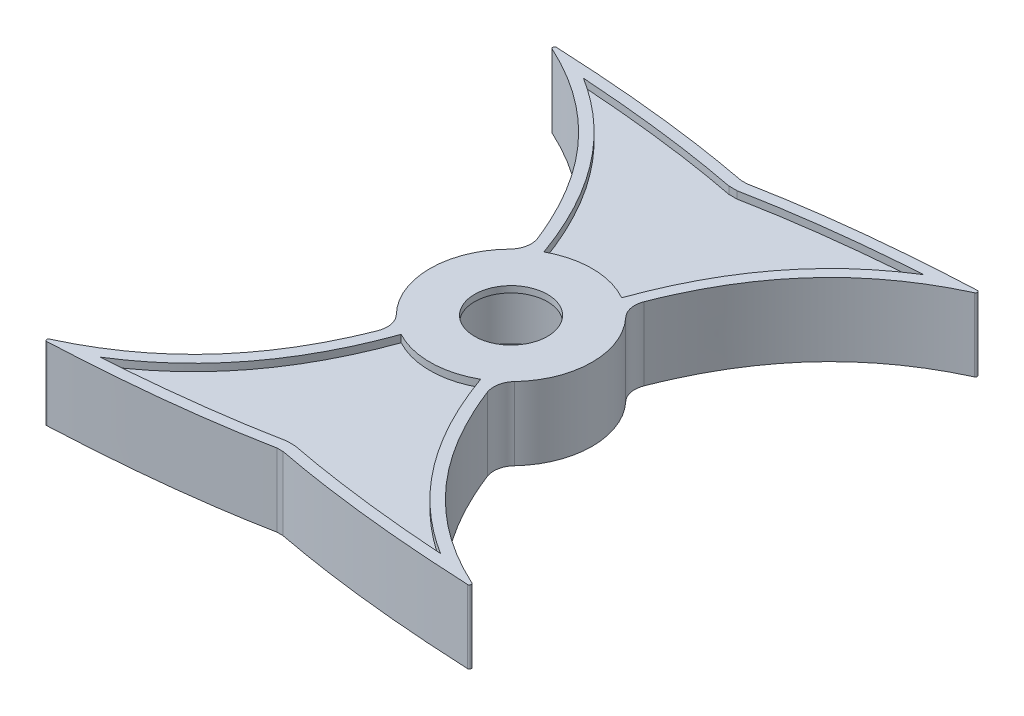
from build123d import *

# Parameters (mm, degrees)
BOSS_EXTRUDE1_DEPTH     = 5
BOSS_EXTRUDE2_DEPTH     = 5
CUT_EXTRUDE2_DEPTH      = 1
CUT_EXTRUDE3_DEPTH      = 77.926135777
CUT_EXTRUDE3_DEPTH_BACK = 77.926135777
FILLET1_R               = 0.25
CUT_EXTRUDE4_START      = -10
CUT_EXTRUDE4_DEPTH      = 1
SKETCH16_R              = 11.125
BOSS_EXTRUDE3_DEPTH     = 5
FILLET2_R               = 3
SKETCH16_3_R            = 8.125
SKETCH16_3_R_2          = 5
CUT_EXTRUDE5_DEPTH      = 4.125
SKETCH16_4_R            = 5
CUT_EXTRUDE6_DEPTH      = 76.97165183
CUT_EXTRUDE6_DEPTH_BACK = 76.97165183


with BuildPart() as part:
    # Sketch2 → Boss-Extrude1 (new, symmetric)
    with BuildSketch(Plane(origin=(0, 0, 0), x_dir=(1, 0, 0), z_dir=(0, 1, 0))):
        with BuildLine():
            add(Edge.make_bspline(
                [(5.058042735, 38.105157157), (3.146372832, 43.741321053), (0.130284217, 48.940308155)],
                knots=[0, 0, 0, 1, 1, 1], degree=2))
            Line((0.130284217, 48.940308155), (0.130284217, 0))
            Line((0.130284217, 0), (0.260568434, 0))
            add(Edge.make_bspline(
                [(5.058042735, 38.105157157), (1.841597364, 25.695767452), (1.424721162, 11.959182325), (0.260568434, 0)],
                knots=[0.522378338, 0.522378338, 0.522378338, 0.522378338, 1, 1, 1, 1], degree=3))
        make_face()
        with BuildLine():
            Line((0.130284217, 0), (0.130284217, 48.940308155))
            add(Edge.make_bspline(
                [(-4.797474301, 38.105157157), (-2.885804398, 43.741321053), (0.130284217, 48.940308155)],
                knots=[0, 0, 0, 1, 1, 1], degree=2))
            add(Edge.make_bspline(
                [(-4.797474301, 38.105157157), (-1.58102893, 25.695767452), (-1.164152728, 11.959182325), (0, 0)],
                knots=[0.522378338, 0.522378338, 0.522378338, 0.522378338, 1, 1, 1, 1], degree=3))
            Line((0, 0), (0.130284217, 0))
        make_face()
        with BuildLine():
            add(Edge.make_bspline(
                [(-4.797474301, 38.105157157), (-2.885804398, 43.741321053), (0.130284217, 48.940308155)],
                knots=[0, 0, 0, 1, 1, 1], degree=2))
            add(Edge.make_bspline(
                [(-5.284185414, 56.665905019), (-2.134774898, 53.195096173), (0.130284217, 48.940308155)],
                knots=[0.737966039, 0.737966039, 0.737966039, 1, 1, 1], degree=2))
            add(Edge.make_bspline(
                [(-9.954353034, 51.660616755), (-7.85501617, 54.382545798), (-5.284185414, 56.665905019)],
                knots=[0, 0, 0, 0.508320354, 0.508320354, 0.508320354], degree=2))
            add(Edge.make_bspline(
                [(-9.954353034, 51.660616755), (-7.686471873, 47.456371568), (-6.034820164, 42.878969621), (-4.797474301, 38.105157157)],
                knots=[0.338640354, 0.338640354, 0.338640354, 0.338640354, 0.522378338, 0.522378338, 0.522378338, 0.522378338], degree=3))
        make_face()
        with BuildLine():
            Line((0.130284217, 48.940308155), (0.130284217, 60.672799159))
            add(Edge.make_bspline(
                [(-5.284185414, 56.665905019), (-2.797515059, 58.874514696), (0.130284217, 60.672799159)],
                knots=[0.508320354, 0.508320354, 0.508320354, 1, 1, 1], degree=2))
            add(Edge.make_bspline(
                [(-5.284185414, 56.665905019), (-2.134774898, 53.195096173), (0.130284217, 48.940308155)],
                knots=[0.737966039, 0.737966039, 0.737966039, 1, 1, 1], degree=2))
        make_face()
        with BuildLine():
            add(Edge.make_bspline(
                [(5.544753848, 56.665905019), (3.058083493, 58.874514696), (0.130284217, 60.672799159)],
                knots=[0.508320354, 0.508320354, 0.508320354, 1, 1, 1], degree=2))
            Line((0.130284217, 60.672799159), (0.130284217, 48.940308155))
            add(Edge.make_bspline(
                [(5.544753848, 56.665905019), (2.395343332, 53.195096173), (0.130284217, 48.940308155)],
                knots=[0.737966039, 0.737966039, 0.737966039, 1, 1, 1], degree=2))
        make_face()
        with BuildLine():
            add(Edge.make_bspline(
                [(5.544753848, 56.665905019), (2.395343332, 53.195096173), (0.130284217, 48.940308155)],
                knots=[0.737966039, 0.737966039, 0.737966039, 1, 1, 1], degree=2))
            add(Edge.make_bspline(
                [(5.058042735, 38.105157157), (3.146372832, 43.741321053), (0.130284217, 48.940308155)],
                knots=[0, 0, 0, 1, 1, 1], degree=2))
            add(Edge.make_bspline(
                [(10.214921468, 51.660616755), (7.947040307, 47.456371568), (6.295388597, 42.878969621), (5.058042735, 38.105157157)],
                knots=[0.338640354, 0.338640354, 0.338640354, 0.338640354, 0.522378338, 0.522378338, 0.522378338, 0.522378338], degree=3))
            add(Edge.make_bspline(
                [(10.214921468, 51.660616755), (8.115584604, 54.382545798), (5.544753848, 56.665905019)],
                knots=[0, 0, 0, 0.508320354, 0.508320354, 0.508320354], degree=2))
        make_face()
        with BuildLine():
            add(Edge.make_bspline(
                [(12.371854568, 62.583668492), (8.55448151, 59.982776333), (5.544753848, 56.665905019)],
                knots=[0.487553825, 0.487553825, 0.487553825, 0.737966039, 0.737966039, 0.737966039], degree=2))
            add(Edge.make_bspline(
                [(10.214921468, 51.660616755), (8.115584604, 54.382545798), (5.544753848, 56.665905019)],
                knots=[0, 0, 0, 0.508320354, 0.508320354, 0.508320354], degree=2))
            add(Edge.make_bspline(
                [(16.684475146, 60.672799159), (14.096083486, 57.947112928), (11.970804186, 54.915708597), (10.214921468, 51.660616755)],
                knots=[0.196383186, 0.196383186, 0.196383186, 0.196383186, 0.338640354, 0.338640354, 0.338640354, 0.338640354], degree=3))
            add(Edge.make_bspline(
                [(12.371854568, 62.583668492), (14.552793974, 61.680828431), (16.684475146, 60.672799159)],
                knots=[0.731382858, 0.731382858, 0.731382858, 1, 1, 1], degree=2))
        make_face()
        with BuildLine():
            add(Edge.make_bspline(
                [(7.660000207, 64.391156365), (3.798429333, 62.755657085), (0.130284217, 60.672799159)],
                knots=[0.732822154, 0.732822154, 0.732822154, 1, 1, 1], degree=2))
            add(Edge.make_bspline(
                [(5.544753848, 56.665905019), (3.058083493, 58.874514696), (0.130284217, 60.672799159)],
                knots=[0.508320354, 0.508320354, 0.508320354, 1, 1, 1], degree=2))
            add(Edge.make_bspline(
                [(12.371854568, 62.583668492), (8.55448151, 59.982776333), (5.544753848, 56.665905019)],
                knots=[0.487553825, 0.487553825, 0.487553825, 0.737966039, 0.737966039, 0.737966039], degree=2))
            add(Edge.make_bspline(
                [(7.660000207, 64.391156365), (10.04398678, 63.547332265), (12.371854568, 62.583668492)],
                knots=[0.444669165, 0.444669165, 0.444669165, 0.731382858, 0.731382858, 0.731382858], degree=2))
        make_face()
        with BuildLine():
            add(Edge.make_bspline(
                [(30.29838823, 69.997414324), (24.713486318, 67.615695548), (20.257698272, 64.435554705), (16.684475146, 60.672799159)],
                knots=[0, 0, 0, 0, 0.196383186, 0.196383186, 0.196383186, 0.196383186], degree=3))
            add(Edge.make_bspline(
                [(30.29838823, 69.997414324), (19.804298872, 67.647618444), (12.371854568, 62.583668492)],
                knots=[0, 0, 0, 0.487553825, 0.487553825, 0.487553825], degree=2))
            add(Edge.make_bspline(
                [(12.371854568, 62.583668492), (14.552793974, 61.680828431), (16.684475146, 60.672799159)],
                knots=[0.731382858, 0.731382858, 0.731382858, 1, 1, 1], degree=2))
        make_face()
        with BuildLine():
            add(Edge.make_bspline(
                [(30.29838823, 69.997414324), (18.251614468, 68.877045154), (7.660000207, 64.391156365)],
                knots=[0, 0, 0, 0.732822154, 0.732822154, 0.732822154], degree=2))
            add(Edge.make_bspline(
                [(7.660000207, 64.391156365), (10.04398678, 63.547332265), (12.371854568, 62.583668492)],
                knots=[0.444669165, 0.444669165, 0.444669165, 0.731382858, 0.731382858, 0.731382858], degree=2))
            add(Edge.make_bspline(
                [(30.29838823, 69.997414324), (19.804298872, 67.647618444), (12.371854568, 62.583668492)],
                knots=[0, 0, 0, 0.487553825, 0.487553825, 0.487553825], degree=2))
        make_face()
        with BuildLine():
            add(Edge.make_bspline(
                [(30.29838823, 69.997414324), (20.531757919, 69.599100635), (10.054304676, 68.677577885), (0.130284217, 66.720303176)],
                knots=[0, 0, 0, 0, 1, 1, 1, 1], degree=3))
            add(Edge.make_bspline(
                [(0.130284217, 66.720303176), (3.962634698, 65.699857578), (7.660000207, 64.391156365)],
                knots=[0, 0, 0, 0.444669165, 0.444669165, 0.444669165], degree=2))
            add(Edge.make_bspline(
                [(30.29838823, 69.997414324), (18.251614468, 68.877045154), (7.660000207, 64.391156365)],
                knots=[0, 0, 0, 0.732822154, 0.732822154, 0.732822154], degree=2))
        make_face()
        with BuildLine():
            add(Edge.make_bspline(
                [(0.130284217, 66.720303176), (3.962634698, 65.699857578), (7.660000207, 64.391156365)],
                knots=[0, 0, 0, 0.444669165, 0.444669165, 0.444669165], degree=2))
            Line((0.130284217, 66.720303176), (0.130284217, 60.672799159))
            add(Edge.make_bspline(
                [(7.660000207, 64.391156365), (3.798429333, 62.755657085), (0.130284217, 60.672799159)],
                knots=[0.732822154, 0.732822154, 0.732822154, 1, 1, 1], degree=2))
        make_face()
        with BuildLine():
            Line((0.130284217, 60.672799159), (0.130284217, 66.720303176))
            add(Edge.make_bspline(
                [(0.130284217, 66.720303176), (-3.702066264, 65.699857578), (-7.399431773, 64.391156365)],
                knots=[0, 0, 0, 0.444669165, 0.444669165, 0.444669165], degree=2))
            add(Edge.make_bspline(
                [(-7.399431773, 64.391156365), (-3.537860899, 62.755657085), (0.130284217, 60.672799159)],
                knots=[0.732822154, 0.732822154, 0.732822154, 1, 1, 1], degree=2))
        make_face()
        with BuildLine():
            add(Edge.make_bspline(
                [(-5.284185414, 56.665905019), (-2.797515059, 58.874514696), (0.130284217, 60.672799159)],
                knots=[0.508320354, 0.508320354, 0.508320354, 1, 1, 1], degree=2))
            add(Edge.make_bspline(
                [(-7.399431773, 64.391156365), (-3.537860899, 62.755657085), (0.130284217, 60.672799159)],
                knots=[0.732822154, 0.732822154, 0.732822154, 1, 1, 1], degree=2))
            add(Edge.make_bspline(
                [(-7.399431773, 64.391156365), (-9.783418346, 63.547332265), (-12.111286134, 62.583668492)],
                knots=[0.444669165, 0.444669165, 0.444669165, 0.731382858, 0.731382858, 0.731382858], degree=2))
            add(Edge.make_bspline(
                [(-12.111286134, 62.583668492), (-8.293913076, 59.982776333), (-5.284185414, 56.665905019)],
                knots=[0.487553825, 0.487553825, 0.487553825, 0.737966039, 0.737966039, 0.737966039], degree=2))
        make_face()
        with BuildLine():
            add(Edge.make_bspline(
                [(-9.954353034, 51.660616755), (-7.85501617, 54.382545798), (-5.284185414, 56.665905019)],
                knots=[0, 0, 0, 0.508320354, 0.508320354, 0.508320354], degree=2))
            add(Edge.make_bspline(
                [(-12.111286134, 62.583668492), (-8.293913076, 59.982776333), (-5.284185414, 56.665905019)],
                knots=[0.487553825, 0.487553825, 0.487553825, 0.737966039, 0.737966039, 0.737966039], degree=2))
            add(Edge.make_bspline(
                [(-12.111286134, 62.583668492), (-14.29222554, 61.680828431), (-16.423906712, 60.672799159)],
                knots=[0.731382858, 0.731382858, 0.731382858, 1, 1, 1], degree=2))
            add(Edge.make_bspline(
                [(-16.423906712, 60.672799159), (-13.835515052, 57.947112928), (-11.710235752, 54.915708597), (-9.954353034, 51.660616755)],
                knots=[0.196383186, 0.196383186, 0.196383186, 0.196383186, 0.338640354, 0.338640354, 0.338640354, 0.338640354], degree=3))
        make_face()
        with BuildLine():
            add(Edge.make_bspline(
                [(-30.037819796, 69.997414324), (-19.543730438, 67.647618444), (-12.111286134, 62.583668492)],
                knots=[0, 0, 0, 0.487553825, 0.487553825, 0.487553825], degree=2))
            add(Edge.make_bspline(
                [(-30.037819796, 69.997414324), (-24.452917884, 67.615695548), (-19.997129838, 64.435554705), (-16.423906712, 60.672799159)],
                knots=[0, 0, 0, 0, 0.196383186, 0.196383186, 0.196383186, 0.196383186], degree=3))
            add(Edge.make_bspline(
                [(-12.111286134, 62.583668492), (-14.29222554, 61.680828431), (-16.423906712, 60.672799159)],
                knots=[0.731382858, 0.731382858, 0.731382858, 1, 1, 1], degree=2))
        make_face()
        with BuildLine():
            add(Edge.make_bspline(
                [(-7.399431773, 64.391156365), (-9.783418346, 63.547332265), (-12.111286134, 62.583668492)],
                knots=[0.444669165, 0.444669165, 0.444669165, 0.731382858, 0.731382858, 0.731382858], degree=2))
            add(Edge.make_bspline(
                [(-30.037819796, 69.997414324), (-17.991046034, 68.877045154), (-7.399431773, 64.391156365)],
                knots=[0, 0, 0, 0.732822154, 0.732822154, 0.732822154], degree=2))
            add(Edge.make_bspline(
                [(-30.037819796, 69.997414324), (-19.543730438, 67.647618444), (-12.111286134, 62.583668492)],
                knots=[0, 0, 0, 0.487553825, 0.487553825, 0.487553825], degree=2))
        make_face()
        with BuildLine():
            add(Edge.make_bspline(
                [(0.130284217, 66.720303176), (-3.702066264, 65.699857578), (-7.399431773, 64.391156365)],
                knots=[0, 0, 0, 0.444669165, 0.444669165, 0.444669165], degree=2))
            add(Edge.make_bspline(
                [(-30.037819796, 69.997414324), (-20.271189485, 69.599100635), (-9.793736242, 68.677577885), (0.130284217, 66.720303176)],
                knots=[0, 0, 0, 0, 1, 1, 1, 1], degree=3))
            add(Edge.make_bspline(
                [(-30.037819796, 69.997414324), (-17.991046034, 68.877045154), (-7.399431773, 64.391156365)],
                knots=[0, 0, 0, 0.732822154, 0.732822154, 0.732822154], degree=2))
        make_face()
    extrude(amount=BOSS_EXTRUDE1_DEPTH, both=True)

    # Sketch3 → Boss-Extrude2 (add, symmetric)
    with BuildSketch(Plane(origin=(0, 0, 0), x_dir=(1, 0, 0), z_dir=(0, 1, 0))):
        with BuildLine():
            Line((0.260568365, 69.997414339), (7e-08, 69.99741433))
            add(Edge.make_bspline(
                [(-4.797474263, 31.892257053), (-1.581028863, 44.301646789), (-1.164152663, 58.038231966), (7e-08, 69.99741433)],
                knots=[0.522378336, 0.522378336, 0.522378336, 0.522378336, 1, 1, 1, 1], degree=3))
            add(Edge.make_bspline(
                [(-4.797474263, 31.892257053), (-2.885804367, 26.256093217), (0.130284218, 21.057106167)],
                knots=[0, 0, 0, 1, 1, 1], degree=2))
            add(Edge.make_bspline(
                [(5.058042699, 31.892257059), (3.146372802, 26.25609322), (0.130284218, 21.057106167)],
                knots=[0, 0, 0, 1, 1, 1], degree=2))
            add(Edge.make_bspline(
                [(5.058042699, 31.892257059), (1.841597298, 44.301646796), (1.424721098, 58.038231974), (0.260568365, 69.997414339)],
                knots=[0.522378336, 0.522378336, 0.522378336, 0.522378336, 1, 1, 1, 1], degree=3))
        make_face()
        with BuildLine():
            add(Edge.make_bspline(
                [(-4.797474263, 31.892257053), (-2.885804367, 26.256093217), (0.130284218, 21.057106167)],
                knots=[0, 0, 0, 1, 1, 1], degree=2))
            add(Edge.make_bspline(
                [(-9.954352995, 18.336797518), (-7.686471838, 22.541042685), (-6.034820127, 27.118444611), (-4.797474263, 31.892257053)],
                knots=[0.338640353, 0.338640353, 0.338640353, 0.338640353, 0.522378336, 0.522378336, 0.522378336, 0.522378336], degree=3))
            add(Edge.make_bspline(
                [(-9.954352995, 18.336797518), (-7.855016146, 15.614868504), (-5.284185413, 13.331509304)],
                knots=[0, 0, 0, 0.508320352, 0.508320352, 0.508320352], degree=2))
            add(Edge.make_bspline(
                [(-5.284185413, 13.331509304), (-2.134774897, 16.802318149), (0.130284218, 21.057106167)],
                knots=[0.737966039, 0.737966039, 0.737966039, 1, 1, 1], degree=2))
        make_face()
        with BuildLine():
            add(Edge.make_bspline(
                [(10.214921433, 18.336797522), (7.947040274, 22.54104269), (6.295388563, 27.118444616), (5.058042699, 31.892257059)],
                knots=[0.338640353, 0.338640353, 0.338640353, 0.338640353, 0.522378336, 0.522378336, 0.522378336, 0.522378336], degree=3))
            add(Edge.make_bspline(
                [(5.058042699, 31.892257059), (3.146372802, 26.25609322), (0.130284218, 21.057106167)],
                knots=[0, 0, 0, 1, 1, 1], degree=2))
            add(Edge.make_bspline(
                [(5.544753848, 13.331509305), (2.395343333, 16.80231815), (0.130284218, 21.057106167)],
                knots=[0.737966039, 0.737966039, 0.737966039, 1, 1, 1], degree=2))
            add(Edge.make_bspline(
                [(10.214921433, 18.336797522), (8.115584582, 15.614868506), (5.544753848, 13.331509305)],
                knots=[0, 0, 0, 0.508320352, 0.508320352, 0.508320352], degree=2))
        make_face()
        with BuildLine():
            add(Edge.make_bspline(
                [(5.544753848, 13.331509305), (2.395343333, 16.80231815), (0.130284218, 21.057106167)],
                knots=[0.737966039, 0.737966039, 0.737966039, 1, 1, 1], degree=2))
            add(Edge.make_bspline(
                [(-5.284185413, 13.331509304), (-2.134774897, 16.802318149), (0.130284218, 21.057106167)],
                knots=[0.737966039, 0.737966039, 0.737966039, 1, 1, 1], degree=2))
            add(Edge.make_bspline(
                [(-5.284185413, 13.331509304), (-2.797515058, 11.122899628), (0.130284217, 9.324615165)],
                knots=[0.508320352, 0.508320352, 0.508320352, 1, 1, 1], degree=2))
            add(Edge.make_bspline(
                [(5.544753848, 13.331509305), (3.058083493, 11.122899628), (0.130284217, 9.324615165)],
                knots=[0.508320352, 0.508320352, 0.508320352, 1, 1, 1], degree=2))
        make_face()
        with BuildLine():
            add(Edge.make_bspline(
                [(16.684475107, 9.324615149), (14.09608345, 12.050301371), (11.970804151, 15.081705692), (10.214921433, 18.336797522)],
                knots=[0.196383186, 0.196383186, 0.196383186, 0.196383186, 0.338640353, 0.338640353, 0.338640353, 0.338640353], degree=3))
            add(Edge.make_bspline(
                [(10.214921433, 18.336797522), (8.115584582, 15.614868506), (5.544753848, 13.331509305)],
                knots=[0, 0, 0, 0.508320352, 0.508320352, 0.508320352], degree=2))
            add(Edge.make_bspline(
                [(12.371854568, 7.413745832), (8.55448151, 10.014637991), (5.544753848, 13.331509305)],
                knots=[0.487553824, 0.487553824, 0.487553824, 0.737966039, 0.737966039, 0.737966039], degree=2))
            add(Edge.make_bspline(
                [(12.371854568, 7.413745832), (14.552793952, 8.316585884), (16.684475102, 9.324615144)],
                knots=[0.73138286, 0.73138286, 0.73138286, 1, 1, 1], degree=2))
        make_face()
        with BuildLine():
            add(Edge.make_bspline(
                [(12.371854568, 7.413745832), (8.55448151, 10.014637991), (5.544753848, 13.331509305)],
                knots=[0.487553824, 0.487553824, 0.487553824, 0.737966039, 0.737966039, 0.737966039], degree=2))
            add(Edge.make_bspline(
                [(5.544753848, 13.331509305), (3.058083493, 11.122899628), (0.130284217, 9.324615165)],
                knots=[0.508320352, 0.508320352, 0.508320352, 1, 1, 1], degree=2))
            add(Edge.make_bspline(
                [(7.660000208, 5.606257959), (3.798429333, 7.241757239), (0.130284217, 9.324615165)],
                knots=[0.732822153, 0.732822153, 0.732822153, 1, 1, 1], degree=2))
            add(Edge.make_bspline(
                [(7.660000208, 5.606257959), (10.043986781, 6.450082059), (12.371854568, 7.413745832)],
                knots=[0.444669167, 0.444669167, 0.444669167, 0.73138286, 0.73138286, 0.73138286], degree=2))
        make_face()
        with BuildLine():
            add(Edge.make_bspline(
                [(30.298388161, 1.6e-08), (24.713486264, 2.381718785), (20.257698228, 5.561859617), (16.684475107, 9.324615149)],
                knots=[0, 0, 0, 0, 0.196383186, 0.196383186, 0.196383186, 0.196383186], degree=3))
            add(Edge.make_bspline(
                [(12.371854568, 7.413745832), (14.552793952, 8.316585884), (16.684475102, 9.324615144)],
                knots=[0.73138286, 0.73138286, 0.73138286, 1, 1, 1], degree=2))
            add(Edge.make_bspline(
                [(30.298388161, 1.5e-08), (19.804298848, 2.349795897), (12.371854568, 7.413745832)],
                knots=[0, 0, 0, 0.487553824, 0.487553824, 0.487553824], degree=2))
        make_face()
        with BuildLine():
            add(Edge.make_bspline(
                [(30.298388161, 1.5e-08), (19.804298848, 2.349795897), (12.371854568, 7.413745832)],
                knots=[0, 0, 0, 0.487553824, 0.487553824, 0.487553824], degree=2))
            add(Edge.make_bspline(
                [(7.660000208, 5.606257959), (10.043986781, 6.450082059), (12.371854568, 7.413745832)],
                knots=[0.444669167, 0.444669167, 0.444669167, 0.73138286, 0.73138286, 0.73138286], degree=2))
            add(Edge.make_bspline(
                [(30.298388161, 1.5e-08), (18.251614437, 1.120369185), (7.660000208, 5.606257959)],
                knots=[0, 0, 0, 0.732822153, 0.732822153, 0.732822153], degree=2))
        make_face()
        with BuildLine():
            add(Edge.make_bspline(
                [(30.298388161, 1.6e-08), (20.531757873, 0.398313701), (10.054304654, 1.319836446), (0.130284217, 3.277111148)],
                knots=[0, 0, 0, 0, 1, 1, 1, 1], degree=3))
            add(Edge.make_bspline(
                [(30.298388161, 1.5e-08), (18.251614437, 1.120369185), (7.660000208, 5.606257959)],
                knots=[0, 0, 0, 0.732822153, 0.732822153, 0.732822153], degree=2))
            add(Edge.make_bspline(
                [(0.130284217, 3.277111148), (3.962634699, 4.297556746), (7.660000208, 5.606257959)],
                knots=[0, 0, 0, 0.444669167, 0.444669167, 0.444669167], degree=2))
        make_face()
        with BuildLine():
            add(Edge.make_bspline(
                [(7.660000208, 5.606257959), (3.798429333, 7.241757239), (0.130284217, 9.324615165)],
                knots=[0.732822153, 0.732822153, 0.732822153, 1, 1, 1], degree=2))
            add(Edge.make_bspline(
                [(-7.399431774, 5.606257959), (-3.537860899, 7.241757239), (0.130284217, 9.324615165)],
                knots=[0.732822153, 0.732822153, 0.732822153, 1, 1, 1], degree=2))
            add(Edge.make_bspline(
                [(0.130284217, 3.277111148), (-3.702066265, 4.297556746), (-7.399431774, 5.606257959)],
                knots=[0, 0, 0, 0.444669166, 0.444669166, 0.444669166], degree=2))
            add(Edge.make_bspline(
                [(0.130284217, 3.277111148), (3.962634699, 4.297556746), (7.660000208, 5.606257959)],
                knots=[0, 0, 0, 0.444669167, 0.444669167, 0.444669167], degree=2))
        make_face()
        with BuildLine():
            add(Edge.make_bspline(
                [(-5.284185413, 13.331509304), (-2.797515058, 11.122899628), (0.130284217, 9.324615165)],
                knots=[0.508320352, 0.508320352, 0.508320352, 1, 1, 1], degree=2))
            add(Edge.make_bspline(
                [(-12.111286133, 7.413745831), (-8.293913075, 10.01463799), (-5.284185413, 13.331509304)],
                knots=[0.487553824, 0.487553824, 0.487553824, 0.737966039, 0.737966039, 0.737966039], degree=2))
            add(Edge.make_bspline(
                [(-7.399431774, 5.606257959), (-9.783418346, 6.450082059), (-12.111286133, 7.413745831)],
                knots=[0.444669166, 0.444669166, 0.444669166, 0.73138286, 0.73138286, 0.73138286], degree=2))
            add(Edge.make_bspline(
                [(-7.399431774, 5.606257959), (-3.537860899, 7.241757239), (0.130284217, 9.324615165)],
                knots=[0.732822153, 0.732822153, 0.732822153, 1, 1, 1], degree=2))
        make_face()
        with BuildLine():
            add(Edge.make_bspline(
                [(-9.954352995, 18.336797518), (-7.855016146, 15.614868504), (-5.284185413, 13.331509304)],
                knots=[0, 0, 0, 0.508320352, 0.508320352, 0.508320352], degree=2))
            add(Edge.make_bspline(
                [(-16.423906668, 9.324615144), (-13.835515011, 12.050301366), (-11.710235713, 15.081705687), (-9.954352995, 18.336797518)],
                knots=[0.196383186, 0.196383186, 0.196383186, 0.196383186, 0.338640353, 0.338640353, 0.338640353, 0.338640353], degree=3))
            add(Edge.make_bspline(
                [(-12.111286133, 7.413745831), (-14.292225518, 8.316585884), (-16.423906668, 9.324615144)],
                knots=[0.73138286, 0.73138286, 0.73138286, 1, 1, 1], degree=2))
            add(Edge.make_bspline(
                [(-12.111286133, 7.413745831), (-8.293913075, 10.01463799), (-5.284185413, 13.331509304)],
                knots=[0.487553824, 0.487553824, 0.487553824, 0.737966039, 0.737966039, 0.737966039], degree=2))
        make_face()
        with BuildLine():
            add(Edge.make_bspline(
                [(-12.111286133, 7.413745831), (-14.292225518, 8.316585884), (-16.423906668, 9.324615144)],
                knots=[0.73138286, 0.73138286, 0.73138286, 1, 1, 1], degree=2))
            add(Edge.make_bspline(
                [(-30.037819727, 6e-09), (-24.452917827, 2.381718777), (-19.99712979, 5.56185961), (-16.423906668, 9.324615144)],
                knots=[0, 0, 0, 0, 0.196383186, 0.196383186, 0.196383186, 0.196383186], degree=3))
            add(Edge.make_bspline(
                [(-30.037819727, 1.5e-08), (-19.543730414, 2.349795897), (-12.111286133, 7.413745831)],
                knots=[0, 0, 0, 0.487553824, 0.487553824, 0.487553824], degree=2))
        make_face()
        with BuildLine():
            add(Edge.make_bspline(
                [(-7.399431774, 5.606257959), (-9.783418346, 6.450082059), (-12.111286133, 7.413745831)],
                knots=[0.444669166, 0.444669166, 0.444669166, 0.73138286, 0.73138286, 0.73138286], degree=2))
            add(Edge.make_bspline(
                [(-30.037819727, 1.5e-08), (-19.543730414, 2.349795897), (-12.111286133, 7.413745831)],
                knots=[0, 0, 0, 0.487553824, 0.487553824, 0.487553824], degree=2))
            add(Edge.make_bspline(
                [(-30.037819727, 1.5e-08), (-17.991046003, 1.120369185), (-7.399431774, 5.606257959)],
                knots=[0, 0, 0, 0.732822153, 0.732822153, 0.732822153], degree=2))
        make_face()
        with BuildLine():
            add(Edge.make_bspline(
                [(-30.037819727, 1.5e-08), (-17.991046003, 1.120369185), (-7.399431774, 5.606257959)],
                knots=[0, 0, 0, 0.732822153, 0.732822153, 0.732822153], degree=2))
            add(Edge.make_bspline(
                [(-30.037819727, 6e-09), (-20.271189438, 0.398313695), (-9.793736219, 1.319836443), (0.130284217, 3.277111148)],
                knots=[0, 0, 0, 0, 1, 1, 1, 1], degree=3))
            add(Edge.make_bspline(
                [(0.130284217, 3.277111148), (-3.702066265, 4.297556746), (-7.399431774, 5.606257959)],
                knots=[0, 0, 0, 0.444669166, 0.444669166, 0.444669166], degree=2))
        make_face()
    extrude(amount=BOSS_EXTRUDE2_DEPTH, both=True)

    # Sketch14 → Cut-Extrude2 (cut)
    with BuildSketch(Plane(origin=(0, 5, 0), x_dir=(1, 0, 0), z_dir=(0, 1, 0))):
        with BuildLine():
            add(Edge.make_bspline(
                [(-23.207664625, 68.130399258), (-21.307159923, 68.003418156), (-17.52218997, 67.706716781), (-11.778865319, 67.101728311), (-6.057457401, 66.319521997), (-2.309031242, 65.666194605), (-0.43636306, 65.302944568)],
                knots=[-0.004745399, -0.004745399, -0.004745399, -0.004745399, 0.184616758, 0.373978916, 0.563341073, 0.752703231, 0.752703231, 0.752703231, 0.752703231], degree=3))
            Line((-0.43636306, 65.302944568), (0.696931494, 65.302944568))
            add(Edge.make_bspline(
                [(0.696931494, 65.302944568), (2.569599676, 65.666194605), (6.318025835, 66.319521997), (12.039433753, 67.101728311), (17.782758404, 67.706716781), (21.567728357, 68.003418156), (23.468233059, 68.130399258)],
                knots=[0.233116381, 0.233116381, 0.233116381, 0.233116381, 0.422478538, 0.611840696, 0.801202853, 0.990565011, 0.990565011, 0.990565011, 0.990565011], degree=3))
            add(Edge.make_bspline(
                [(23.468233059, 68.130399258), (22.712084851, 67.656518504), (21.217534286, 66.65137107), (18.460753946, 64.523699589), (15.36226089, 61.610167554), (12.185658239, 57.77102173), (8.605723922, 52.254674876), (5.920851026, 46.237284042), (3.927581119, 39.894222563), (3.138917517, 36.632422948), (2.779027509, 34.998707011)],
                knots=[-0.004074911, -0.004074911, -0.004074911, -0.004074911, 0.02651215, 0.057099211, 0.118273332, 0.179447453, 0.240621575, 0.362969818, 0.424143939, 0.48531806, 0.48531806, 0.48531806, 0.48531806], degree=3))
            add(Edge.make_bspline(
                [(2.779027509, 34.998707011), (3.13891752, 33.364991089), (3.927581127, 30.103191505), (5.92085104, 23.760130086), (8.605723937, 17.742739312), (12.185658244, 12.226392512), (15.36226088, 8.387246725), (18.460753917, 5.473714717), (21.217534238, 3.346043255), (22.712084791, 2.34089583), (23.468232994, 1.86701508)],
                knots=[0.076587437, 0.076587437, 0.076587437, 0.076587437, 0.137761558, 0.198935679, 0.32128392, 0.382458041, 0.443632162, 0.504806283, 0.535393344, 0.565980404, 0.565980404, 0.565980404, 0.565980404], degree=3))
            add(Edge.make_bspline(
                [(23.468232994, 1.86701508), (21.567728302, 1.99399618), (17.782758372, 2.290697553), (12.039433755, 2.895686018), (6.31802587, 3.677892324), (2.569599732, 4.331219709), (0.69693156, 4.694469743)],
                knots=[-0.004745399, -0.004745399, -0.004745399, -0.004745399, 0.184616758, 0.373978914, 0.563341071, 0.752703228, 0.752703228, 0.752703228, 0.752703228], degree=3))
            Line((0.69693156, 4.694469743), (-0.436363126, 4.694469743))
            add(Edge.make_bspline(
                [(-0.436363126, 4.694469743), (-2.309031297, 4.331219709), (-6.057457434, 3.677892322), (-11.778865318, 2.895686014), (-17.522189934, 2.290697547), (-21.307159864, 1.993996174), (-23.207664555, 1.867015073)],
                knots=[0.233116381, 0.233116381, 0.233116381, 0.233116381, 0.422478538, 0.611840695, 0.801202852, 0.990565009, 0.990565009, 0.990565009, 0.990565009], degree=3))
            add(Edge.make_bspline(
                [(-23.207664555, 1.867015073), (-22.451516352, 2.340895823), (-20.956965799, 3.346043249), (-18.200185479, 5.473714711), (-15.101692442, 8.387246719), (-11.925089807, 12.226392506), (-8.3451555, 17.742739306), (-5.660282604, 23.76013008), (-3.667012691, 30.103191498), (-2.878349084, 33.364991083), (-2.518459073, 34.998707004)],
                knots=[-0.004074911, -0.004074911, -0.004074911, -0.004074911, 0.02651215, 0.05709921, 0.118273331, 0.179447452, 0.240621573, 0.362969815, 0.424143936, 0.485318057, 0.485318057, 0.485318057, 0.485318057], degree=3))
            add(Edge.make_bspline(
                [(-2.518459073, 34.998707004), (-2.878349082, 36.632422942), (-3.667012684, 39.894222557), (-5.66028259, 46.237284038), (-8.345155486, 52.254674872), (-11.925089804, 57.771021728), (-15.101692455, 61.610167553), (-18.200185512, 64.523699588), (-20.956965852, 66.65137107), (-22.451516416, 67.656518504), (-23.207664625, 68.130399258)],
                knots=[0.076587437, 0.076587437, 0.076587437, 0.076587437, 0.137761558, 0.19893568, 0.321283923, 0.382458044, 0.443632165, 0.504806287, 0.535393347, 0.565980408, 0.565980408, 0.565980408, 0.565980408], degree=3))
        make_face()
    extrude(amount=-CUT_EXTRUDE2_DEPTH, mode=Mode.SUBTRACT)

    # Sketch15 → Cut-Extrude3 (cut, two sides)
    with BuildSketch(Plane(origin=(0, 5, 0), x_dir=(1, 0, 0), z_dir=(0, 1, 0))) as cut_extrude3_sk:
        with BuildLine():
            Line((-0.292225434, 66.802944568), (0.55279387, 66.802944568))
            add(Edge.make_bspline(
                [(30.298388161, 69.997414308), (20.670252532, 69.604748877), (10.351310458, 68.703607777), (0.55279387, 66.802944568)],
                knots=[0, 0, 0, 0, 0.985819611, 0.985819611, 0.985819611, 0.985819611], degree=3))
            Line((30.298388161, 69.997414308), (-30.037819798, 69.997414324))
            add(Edge.make_bspline(
                [(-30.037819798, 69.997414324), (-20.409684098, 69.604748877), (-10.090742023, 68.703607777), (-0.292225434, 66.802944568)],
                knots=[0, 0, 0, 0, 0.985819611, 0.985819611, 0.985819611, 0.985819611], degree=3))
        make_face()
        with BuildLine():
            Line((-0.292225502, 3.194469743), (0.552793936, 3.194469743))
            add(Edge.make_bspline(
                [(30.298388093, 3.1e-08), (20.670252508, 0.392665458), (10.351310482, 1.29380655), (0.552793936, 3.194469743)],
                knots=[0, 0, 0, 0, 0.985819609, 0.985819609, 0.985819609, 0.985819609], degree=3))
            Line((30.298388093, 3.1e-08), (-30.037819659, 3.1e-08))
            add(Edge.make_bspline(
                [(-30.037819659, 3.1e-08), (-20.409684073, 0.392665451), (-10.090742048, 1.293806547), (-0.292225502, 3.194469743)],
                knots=[0, 0, 0, 0, 0.985819609, 0.985819609, 0.985819609, 0.985819609], degree=3))
        make_face()
    extrude(amount=CUT_EXTRUDE3_DEPTH, mode=Mode.SUBTRACT)
    extrude(cut_extrude3_sk.sketch, amount=-CUT_EXTRUDE3_DEPTH_BACK, mode=Mode.SUBTRACT)

    # Fillet1
    fillet1_edges = [part.edges().sort_by_distance(p)[0] for p in [
        (30.29838823, 2.5, -69.997414324),
        (30.298388161, 2.5, -1.6e-08),
        (-30.037819727, 2.5, -1.1e-08),
        (-30.037819796, 2.5, -69.997414324),
    ]]
    fillet(fillet1_edges, radius=FILLET1_R)

    # Sketch14_3 → Cut-Extrude4 (cut)
    with BuildSketch(Plane(origin=(0, 5, 0), x_dir=(1, 0, 0), z_dir=(0, 1, 0)).offset(CUT_EXTRUDE4_START)):
        with BuildLine():
            add(Edge.make_bspline(
                [(-23.207664625, 68.130399258), (-21.307159923, 68.003418156), (-17.52218997, 67.706716781), (-11.778865319, 67.101728311), (-6.057457401, 66.319521997), (-2.309031242, 65.666194605), (-0.43636306, 65.302944568)],
                knots=[-0.004745399, -0.004745399, -0.004745399, -0.004745399, 0.184616758, 0.373978916, 0.563341073, 0.752703231, 0.752703231, 0.752703231, 0.752703231], degree=3))
            Line((-0.43636306, 65.302944568), (0.696931494, 65.302944568))
            add(Edge.make_bspline(
                [(0.696931494, 65.302944568), (2.569599676, 65.666194605), (6.318025835, 66.319521997), (12.039433753, 67.101728311), (17.782758404, 67.706716781), (21.567728357, 68.003418156), (23.468233059, 68.130399258)],
                knots=[0.233116381, 0.233116381, 0.233116381, 0.233116381, 0.422478538, 0.611840696, 0.801202853, 0.990565011, 0.990565011, 0.990565011, 0.990565011], degree=3))
            add(Edge.make_bspline(
                [(23.468233059, 68.130399258), (22.712084851, 67.656518504), (21.217534286, 66.65137107), (18.460753946, 64.523699589), (15.36226089, 61.610167554), (12.185658239, 57.77102173), (8.605723922, 52.254674876), (5.920851026, 46.237284042), (3.927581119, 39.894222563), (3.138917517, 36.632422948), (2.779027509, 34.998707011)],
                knots=[-0.004074911, -0.004074911, -0.004074911, -0.004074911, 0.02651215, 0.057099211, 0.118273332, 0.179447453, 0.240621575, 0.362969818, 0.424143939, 0.48531806, 0.48531806, 0.48531806, 0.48531806], degree=3))
            add(Edge.make_bspline(
                [(2.779027509, 34.998707011), (3.13891752, 33.364991089), (3.927581127, 30.103191505), (5.92085104, 23.760130086), (8.605723937, 17.742739312), (12.185658244, 12.226392512), (15.36226088, 8.387246725), (18.460753917, 5.473714717), (21.217534238, 3.346043255), (22.712084791, 2.34089583), (23.468232994, 1.86701508)],
                knots=[0.076587437, 0.076587437, 0.076587437, 0.076587437, 0.137761558, 0.198935679, 0.32128392, 0.382458041, 0.443632162, 0.504806283, 0.535393344, 0.565980404, 0.565980404, 0.565980404, 0.565980404], degree=3))
            add(Edge.make_bspline(
                [(23.468232994, 1.86701508), (21.567728302, 1.99399618), (17.782758372, 2.290697553), (12.039433755, 2.895686018), (6.31802587, 3.677892324), (2.569599732, 4.331219709), (0.69693156, 4.694469743)],
                knots=[-0.004745399, -0.004745399, -0.004745399, -0.004745399, 0.184616758, 0.373978914, 0.563341071, 0.752703228, 0.752703228, 0.752703228, 0.752703228], degree=3))
            Line((0.69693156, 4.694469743), (-0.436363126, 4.694469743))
            add(Edge.make_bspline(
                [(-0.436363126, 4.694469743), (-2.309031297, 4.331219709), (-6.057457434, 3.677892322), (-11.778865318, 2.895686014), (-17.522189934, 2.290697547), (-21.307159864, 1.993996174), (-23.207664555, 1.867015073)],
                knots=[0.233116381, 0.233116381, 0.233116381, 0.233116381, 0.422478538, 0.611840695, 0.801202852, 0.990565009, 0.990565009, 0.990565009, 0.990565009], degree=3))
            add(Edge.make_bspline(
                [(-23.207664555, 1.867015073), (-22.451516352, 2.340895823), (-20.956965799, 3.346043249), (-18.200185479, 5.473714711), (-15.101692442, 8.387246719), (-11.925089807, 12.226392506), (-8.3451555, 17.742739306), (-5.660282604, 23.76013008), (-3.667012691, 30.103191498), (-2.878349084, 33.364991083), (-2.518459073, 34.998707004)],
                knots=[-0.004074911, -0.004074911, -0.004074911, -0.004074911, 0.02651215, 0.05709921, 0.118273331, 0.179447452, 0.240621573, 0.362969815, 0.424143936, 0.485318057, 0.485318057, 0.485318057, 0.485318057], degree=3))
            add(Edge.make_bspline(
                [(-2.518459073, 34.998707004), (-2.878349082, 36.632422942), (-3.667012684, 39.894222557), (-5.66028259, 46.237284038), (-8.345155486, 52.254674872), (-11.925089804, 57.771021728), (-15.101692455, 61.610167553), (-18.200185512, 64.523699588), (-20.956965852, 66.65137107), (-22.451516416, 67.656518504), (-23.207664625, 68.130399258)],
                knots=[0.076587437, 0.076587437, 0.076587437, 0.076587437, 0.137761558, 0.19893568, 0.321283923, 0.382458044, 0.443632165, 0.504806287, 0.535393347, 0.565980408, 0.565980408, 0.565980408, 0.565980408], degree=3))
        make_face()
    extrude(amount=CUT_EXTRUDE4_DEPTH, mode=Mode.SUBTRACT)

    # Sketch16 → Boss-Extrude3 (add, symmetric)
    with BuildSketch(Plane(origin=(0, 0, 0), x_dir=(1, 0, 0), z_dir=(0, 1, 0))):
        with Locations((0, 34.998707012)):
            Circle(SKETCH16_R)
    extrude(amount=BOSS_EXTRUDE3_DEPTH, both=True)

    # Fillet2
    fillet2_edges = [part.edges().sort_by_distance(p)[0] for p in [
        (6.785057892, -2.5, -43.815090307),
        (6.785057924, 2.4999997, -26.182323742),
        (-6.578990009, -2.5, -43.969911806),
        (-6.57899004, 2.4999997, -26.027502241),
    ]]
    fillet(fillet2_edges, radius=FILLET2_R)

    # Sketch16_3 → Cut-Extrude5 (cut, symmetric)
    with BuildSketch(Plane(origin=(0, 0, 0), x_dir=(1, 0, 0), z_dir=(0, 1, 0))):
        with Locations(Location((0, 34.998707012, 0), (0, 0, 270))):
            Circle(SKETCH16_3_R)
        with Locations((0, 34.998707012)):
            Circle(SKETCH16_3_R_2)
    extrude(amount=CUT_EXTRUDE5_DEPTH, both=True, mode=Mode.SUBTRACT)

    # Sketch16_4 → Cut-Extrude6 (cut, two sides)
    with BuildSketch(Plane(origin=(0, 0, 0), x_dir=(1, 0, 0), z_dir=(0, 1, 0))) as cut_extrude6_sk:
        with Locations(Location((0, 34.998707012, 0), (0, 0, 270))):
            Circle(SKETCH16_4_R)
    extrude(amount=CUT_EXTRUDE6_DEPTH, mode=Mode.SUBTRACT)
    extrude(cut_extrude6_sk.sketch, amount=-CUT_EXTRUDE6_DEPTH_BACK, mode=Mode.SUBTRACT)


solid = part.part
